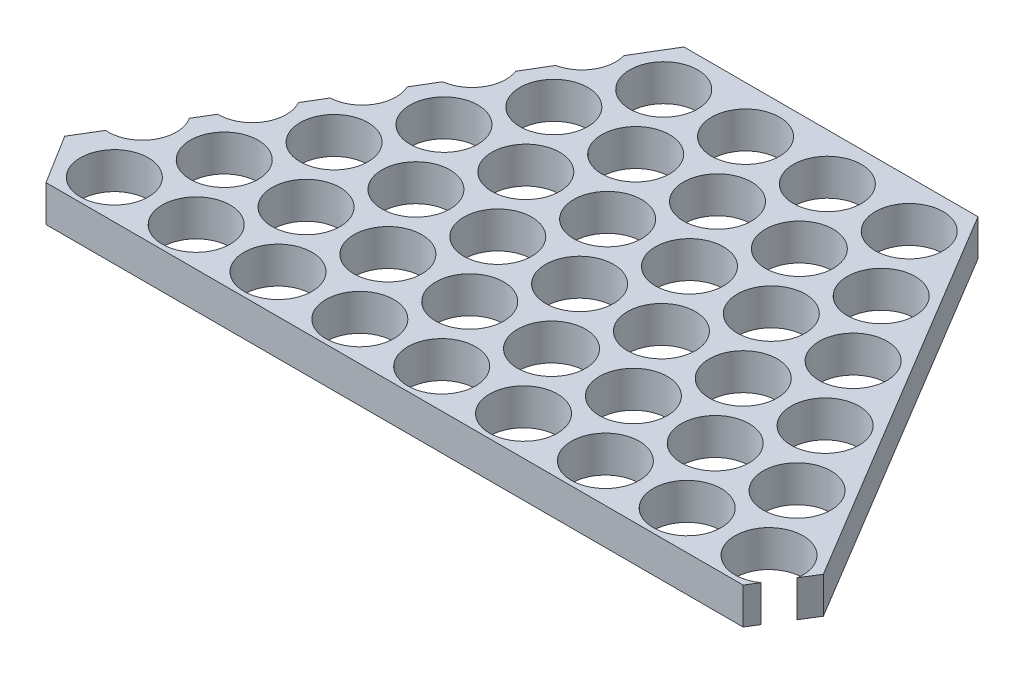
from build123d import *

# Parameters (mm, degrees)
BOSS_EXTRUDE1_DEPTH        = 2
SKETCH2_R                  = 1.868021305
CUT_EXTRUDE1_DEPTH         = 2
LPATTERN1_COUNT            = 4
LPATTERN1_PITCH            = 4.5
LPATTERN2_COUNT            = 6
LPATTERN2_PITCH            = 4.5
LPATTERN3_COUNT            = 9
LPATTERN3_PITCH            = 4.5
LPATTERN3_COPY_1_SKETCH_R  = 1.868021305
LPATTERN3_COPY_1_DEPTH     = 2
LPATTERN3_COPY_2_SKETCH_R  = 1.868021305
LPATTERN3_COPY_2_DEPTH     = 2
LPATTERN3_COPY_3_SKETCH_R  = 1.868021305
LPATTERN3_COPY_3_DEPTH     = 2
LPATTERN3_COPY_4_SKETCH_R  = 1.868021305
LPATTERN3_COPY_4_DEPTH     = 2
LPATTERN3_COPY_5_SKETCH_R  = 1.868021305
LPATTERN3_COPY_5_DEPTH     = 2
LPATTERN3_COPY_6_SKETCH_R  = 1.868021305
LPATTERN3_COPY_6_DEPTH     = 2
LPATTERN3_COPY_7_SKETCH_R  = 1.868021305
LPATTERN3_COPY_7_DEPTH     = 2
LPATTERN3_COPY_8_SKETCH_R  = 1.868021305
LPATTERN3_COPY_8_DEPTH     = 2
LPATTERN3_COPY_9_SKETCH_R  = 1.868021305
LPATTERN3_COPY_9_DEPTH     = 2
LPATTERN3_COPY_10_SKETCH_R = 1.868021305
LPATTERN3_COPY_10_DEPTH    = 2
LPATTERN3_COPY_11_SKETCH_R = 1.868021305
LPATTERN3_COPY_11_DEPTH    = 2
LPATTERN3_COPY_12_SKETCH_R = 1.868021305
LPATTERN3_COPY_12_DEPTH    = 2
LPATTERN3_COPY_13_SKETCH_R = 1.868021305
LPATTERN3_COPY_13_DEPTH    = 2
LPATTERN3_COPY_14_SKETCH_R = 1.868021305
LPATTERN3_COPY_14_DEPTH    = 2
LPATTERN3_COPY_15_SKETCH_R = 1.868021305
LPATTERN3_COPY_15_DEPTH    = 2
LPATTERN3_COPY_16_SKETCH_R = 1.868021305
LPATTERN3_COPY_16_DEPTH    = 2
LPATTERN3_COPY_17_SKETCH_R = 1.868021305
LPATTERN3_COPY_17_DEPTH    = 2
LPATTERN3_COPY_18_SKETCH_R = 1.868021305
LPATTERN3_COPY_18_DEPTH    = 2
LPATTERN3_COPY_19_SKETCH_R = 1.868021305
LPATTERN3_COPY_19_DEPTH    = 2
LPATTERN3_COPY_20_SKETCH_R = 1.868021305
LPATTERN3_COPY_20_DEPTH    = 2
LPATTERN3_COPY_21_SKETCH_R = 1.868021305
LPATTERN3_COPY_21_DEPTH    = 2
LPATTERN3_COPY_22_SKETCH_R = 1.868021305
LPATTERN3_COPY_22_DEPTH    = 2
LPATTERN3_COPY_23_SKETCH_R = 1.868021305
LPATTERN3_COPY_23_DEPTH    = 2
LPATTERN3_COPY_24_SKETCH_R = 1.868021305
LPATTERN3_COPY_24_DEPTH    = 2
LPATTERN3_COPY_25_SKETCH_R = 1.868021305
LPATTERN3_COPY_25_DEPTH    = 2
LPATTERN3_COPY_26_SKETCH_R = 1.868021305
LPATTERN3_COPY_26_DEPTH    = 2
LPATTERN3_COPY_27_SKETCH_R = 1.868021305
LPATTERN3_COPY_27_DEPTH    = 2
LPATTERN3_COPY_28_SKETCH_R = 1.868021305
LPATTERN3_COPY_28_DEPTH    = 2
LPATTERN3_COPY_29_SKETCH_R = 1.868021305
LPATTERN3_COPY_29_DEPTH    = 2
LPATTERN3_COPY_30_SKETCH_R = 1.868021305
LPATTERN3_COPY_30_DEPTH    = 2
LPATTERN3_COPY_31_SKETCH_R = 1.868021305
LPATTERN3_COPY_31_DEPTH    = 2
LPATTERN3_COPY_32_SKETCH_R = 1.868021305
LPATTERN3_COPY_32_DEPTH    = 2
LPATTERN3_COPY_33_SKETCH_R = 1.868021305
LPATTERN3_COPY_33_DEPTH    = 2
LPATTERN3_COPY_34_SKETCH_R = 1.868021305
LPATTERN3_COPY_34_DEPTH    = 2
LPATTERN3_COPY_35_SKETCH_R = 1.868021305
LPATTERN3_COPY_35_DEPTH    = 2
LPATTERN3_COPY_36_SKETCH_R = 1.868021305
LPATTERN3_COPY_36_DEPTH    = 2
LPATTERN3_COPY_37_SKETCH_R = 1.868021305
LPATTERN3_COPY_37_DEPTH    = 2
LPATTERN3_COPY_38_SKETCH_R = 1.868021305
LPATTERN3_COPY_38_DEPTH    = 2
LPATTERN3_COPY_39_SKETCH_R = 1.868021305
LPATTERN3_COPY_39_DEPTH    = 2
LPATTERN3_COPY_40_SKETCH_R = 1.868021305
LPATTERN3_COPY_40_DEPTH    = 2


with BuildPart() as part:
    # Sketch1 → Boss-Extrude1 (new body)
    with BuildSketch(Plane(origin=(0, 0, 0), x_dir=(1, 0, 0), z_dir=(0, 1, 0))):
        Polygon((8.311480428, 12), (-7.85854732, 12), (-20.632588284, -9.27790252), (-18.939417603, -12), (19.392350711, -12), (21.085521392, -9.27790252), align=None)
    extrude(amount=BOSS_EXTRUDE1_DEPTH)

    # Sketch2 → Cut-Extrude1 (cut)
    with BuildSketch(Plane(origin=(0, 2, 0), x_dir=(1, 0, 0), z_dir=(0, 1, 0))):
        with Locations((7.108541754, 9.420480397)):
            Circle(SKETCH2_R)
    cut_extrude1 = extrude(amount=-CUT_EXTRUDE1_DEPTH, mode=Mode.SUBTRACT)

    # LPattern1: Cut-Extrude1 ×4
    with Locations(*[(-i * LPATTERN1_PITCH, 0, 0) for i in range(1, LPATTERN1_COUNT)]):
        add(cut_extrude1, mode=Mode.SUBTRACT)

    # LPattern2: Cut-Extrude1 ×6
    with Locations(*[Vector(0.514712005, 0, 0.857363139) * (i * LPATTERN2_PITCH) for i in range(1, LPATTERN2_COUNT)]):
        add(cut_extrude1, mode=Mode.SUBTRACT)

    # LPattern3: Cut-Extrude1 ×9
    with Locations(*[(-i * LPATTERN3_PITCH, 0, 0) for i in range(1, LPATTERN3_COUNT)]):
        add(cut_extrude1, mode=Mode.SUBTRACT)

    # LPattern3 copy 1 sketch → LPattern3 copy 1 (cut)
    with BuildSketch(Plane(origin=(-2.183795979, 2, 3.858134126), x_dir=(1, 0, 0), z_dir=(0, 1, 0))):
        with Locations((7.108541754, 9.420480397)):
            Circle(LPATTERN3_COPY_1_SKETCH_R)
    extrude(amount=-LPATTERN3_COPY_1_DEPTH, mode=Mode.SUBTRACT)

    # LPattern3 copy 2 sketch → LPattern3 copy 2 (cut)
    with BuildSketch(Plane(origin=(-6.683795979, 2, 3.858134126), x_dir=(1, 0, 0), z_dir=(0, 1, 0))):
        with Locations((7.108541754, 9.420480397)):
            Circle(LPATTERN3_COPY_2_SKETCH_R)
    extrude(amount=-LPATTERN3_COPY_2_DEPTH, mode=Mode.SUBTRACT)

    # LPattern3 copy 3 sketch → LPattern3 copy 3 (cut)
    with BuildSketch(Plane(origin=(-11.183795979, 2, 3.858134126), x_dir=(1, 0, 0), z_dir=(0, 1, 0))):
        with Locations((7.108541754, 9.420480397)):
            Circle(LPATTERN3_COPY_3_SKETCH_R)
    extrude(amount=-LPATTERN3_COPY_3_DEPTH, mode=Mode.SUBTRACT)

    # LPattern3 copy 4 sketch → LPattern3 copy 4 (cut)
    with BuildSketch(Plane(origin=(-15.683795979, 2, 3.858134126), x_dir=(1, 0, 0), z_dir=(0, 1, 0))):
        with Locations((7.108541754, 9.420480397)):
            Circle(LPATTERN3_COPY_4_SKETCH_R)
    extrude(amount=-LPATTERN3_COPY_4_DEPTH, mode=Mode.SUBTRACT)

    # LPattern3 copy 5 sketch → LPattern3 copy 5 (cut)
    with BuildSketch(Plane(origin=(-20.183795979, 2, 3.858134126), x_dir=(1, 0, 0), z_dir=(0, 1, 0))):
        with Locations((7.108541754, 9.420480397)):
            Circle(LPATTERN3_COPY_5_SKETCH_R)
    extrude(amount=-LPATTERN3_COPY_5_DEPTH, mode=Mode.SUBTRACT)

    # LPattern3 copy 6 sketch → LPattern3 copy 6 (cut)
    with BuildSketch(Plane(origin=(-24.683795979, 2, 3.858134126), x_dir=(1, 0, 0), z_dir=(0, 1, 0))):
        with Locations((7.108541754, 9.420480397)):
            Circle(LPATTERN3_COPY_6_SKETCH_R)
    extrude(amount=-LPATTERN3_COPY_6_DEPTH, mode=Mode.SUBTRACT)

    # LPattern3 copy 7 sketch → LPattern3 copy 7 (cut)
    with BuildSketch(Plane(origin=(-29.183795979, 2, 3.858134126), x_dir=(1, 0, 0), z_dir=(0, 1, 0))):
        with Locations((7.108541754, 9.420480397)):
            Circle(LPATTERN3_COPY_7_SKETCH_R)
    extrude(amount=-LPATTERN3_COPY_7_DEPTH, mode=Mode.SUBTRACT)

    # LPattern3 copy 8 sketch → LPattern3 copy 8 (cut)
    with BuildSketch(Plane(origin=(-33.683795979, 2, 3.858134126), x_dir=(1, 0, 0), z_dir=(0, 1, 0))):
        with Locations((7.108541754, 9.420480397)):
            Circle(LPATTERN3_COPY_8_SKETCH_R)
    extrude(amount=-LPATTERN3_COPY_8_DEPTH, mode=Mode.SUBTRACT)

    # LPattern3 copy 9 sketch → LPattern3 copy 9 (cut)
    with BuildSketch(Plane(origin=(0.132408042, 2, 7.716268252), x_dir=(1, 0, 0), z_dir=(0, 1, 0))):
        with Locations((7.108541754, 9.420480397)):
            Circle(LPATTERN3_COPY_9_SKETCH_R)
    extrude(amount=-LPATTERN3_COPY_9_DEPTH, mode=Mode.SUBTRACT)

    # LPattern3 copy 10 sketch → LPattern3 copy 10 (cut)
    with BuildSketch(Plane(origin=(-4.367591958, 2, 7.716268252), x_dir=(1, 0, 0), z_dir=(0, 1, 0))):
        with Locations((7.108541754, 9.420480397)):
            Circle(LPATTERN3_COPY_10_SKETCH_R)
    extrude(amount=-LPATTERN3_COPY_10_DEPTH, mode=Mode.SUBTRACT)

    # LPattern3 copy 11 sketch → LPattern3 copy 11 (cut)
    with BuildSketch(Plane(origin=(-8.867591958, 2, 7.716268252), x_dir=(1, 0, 0), z_dir=(0, 1, 0))):
        with Locations((7.108541754, 9.420480397)):
            Circle(LPATTERN3_COPY_11_SKETCH_R)
    extrude(amount=-LPATTERN3_COPY_11_DEPTH, mode=Mode.SUBTRACT)

    # LPattern3 copy 12 sketch → LPattern3 copy 12 (cut)
    with BuildSketch(Plane(origin=(-13.367591958, 2, 7.716268252), x_dir=(1, 0, 0), z_dir=(0, 1, 0))):
        with Locations((7.108541754, 9.420480397)):
            Circle(LPATTERN3_COPY_12_SKETCH_R)
    extrude(amount=-LPATTERN3_COPY_12_DEPTH, mode=Mode.SUBTRACT)

    # LPattern3 copy 13 sketch → LPattern3 copy 13 (cut)
    with BuildSketch(Plane(origin=(-17.867591958, 2, 7.716268252), x_dir=(1, 0, 0), z_dir=(0, 1, 0))):
        with Locations((7.108541754, 9.420480397)):
            Circle(LPATTERN3_COPY_13_SKETCH_R)
    extrude(amount=-LPATTERN3_COPY_13_DEPTH, mode=Mode.SUBTRACT)

    # LPattern3 copy 14 sketch → LPattern3 copy 14 (cut)
    with BuildSketch(Plane(origin=(-22.367591958, 2, 7.716268252), x_dir=(1, 0, 0), z_dir=(0, 1, 0))):
        with Locations((7.108541754, 9.420480397)):
            Circle(LPATTERN3_COPY_14_SKETCH_R)
    extrude(amount=-LPATTERN3_COPY_14_DEPTH, mode=Mode.SUBTRACT)

    # LPattern3 copy 15 sketch → LPattern3 copy 15 (cut)
    with BuildSketch(Plane(origin=(-26.867591958, 2, 7.716268252), x_dir=(1, 0, 0), z_dir=(0, 1, 0))):
        with Locations((7.108541754, 9.420480397)):
            Circle(LPATTERN3_COPY_15_SKETCH_R)
    extrude(amount=-LPATTERN3_COPY_15_DEPTH, mode=Mode.SUBTRACT)

    # LPattern3 copy 16 sketch → LPattern3 copy 16 (cut)
    with BuildSketch(Plane(origin=(-31.367591958, 2, 7.716268252), x_dir=(1, 0, 0), z_dir=(0, 1, 0))):
        with Locations((7.108541754, 9.420480397)):
            Circle(LPATTERN3_COPY_16_SKETCH_R)
    extrude(amount=-LPATTERN3_COPY_16_DEPTH, mode=Mode.SUBTRACT)

    # LPattern3 copy 17 sketch → LPattern3 copy 17 (cut)
    with BuildSketch(Plane(origin=(2.448612062, 2, 11.574402378), x_dir=(1, 0, 0), z_dir=(0, 1, 0))):
        with Locations((7.108541754, 9.420480397)):
            Circle(LPATTERN3_COPY_17_SKETCH_R)
    extrude(amount=-LPATTERN3_COPY_17_DEPTH, mode=Mode.SUBTRACT)

    # LPattern3 copy 18 sketch → LPattern3 copy 18 (cut)
    with BuildSketch(Plane(origin=(-2.051387938, 2, 11.574402378), x_dir=(1, 0, 0), z_dir=(0, 1, 0))):
        with Locations((7.108541754, 9.420480397)):
            Circle(LPATTERN3_COPY_18_SKETCH_R)
    extrude(amount=-LPATTERN3_COPY_18_DEPTH, mode=Mode.SUBTRACT)

    # LPattern3 copy 19 sketch → LPattern3 copy 19 (cut)
    with BuildSketch(Plane(origin=(-6.551387938, 2, 11.574402378), x_dir=(1, 0, 0), z_dir=(0, 1, 0))):
        with Locations((7.108541754, 9.420480397)):
            Circle(LPATTERN3_COPY_19_SKETCH_R)
    extrude(amount=-LPATTERN3_COPY_19_DEPTH, mode=Mode.SUBTRACT)

    # LPattern3 copy 20 sketch → LPattern3 copy 20 (cut)
    with BuildSketch(Plane(origin=(-11.051387938, 2, 11.574402378), x_dir=(1, 0, 0), z_dir=(0, 1, 0))):
        with Locations((7.108541754, 9.420480397)):
            Circle(LPATTERN3_COPY_20_SKETCH_R)
    extrude(amount=-LPATTERN3_COPY_20_DEPTH, mode=Mode.SUBTRACT)

    # LPattern3 copy 21 sketch → LPattern3 copy 21 (cut)
    with BuildSketch(Plane(origin=(-15.551387938, 2, 11.574402378), x_dir=(1, 0, 0), z_dir=(0, 1, 0))):
        with Locations((7.108541754, 9.420480397)):
            Circle(LPATTERN3_COPY_21_SKETCH_R)
    extrude(amount=-LPATTERN3_COPY_21_DEPTH, mode=Mode.SUBTRACT)

    # LPattern3 copy 22 sketch → LPattern3 copy 22 (cut)
    with BuildSketch(Plane(origin=(-20.051387938, 2, 11.574402378), x_dir=(1, 0, 0), z_dir=(0, 1, 0))):
        with Locations((7.108541754, 9.420480397)):
            Circle(LPATTERN3_COPY_22_SKETCH_R)
    extrude(amount=-LPATTERN3_COPY_22_DEPTH, mode=Mode.SUBTRACT)

    # LPattern3 copy 23 sketch → LPattern3 copy 23 (cut)
    with BuildSketch(Plane(origin=(-24.551387938, 2, 11.574402378), x_dir=(1, 0, 0), z_dir=(0, 1, 0))):
        with Locations((7.108541754, 9.420480397)):
            Circle(LPATTERN3_COPY_23_SKETCH_R)
    extrude(amount=-LPATTERN3_COPY_23_DEPTH, mode=Mode.SUBTRACT)

    # LPattern3 copy 24 sketch → LPattern3 copy 24 (cut)
    with BuildSketch(Plane(origin=(-29.051387938, 2, 11.574402378), x_dir=(1, 0, 0), z_dir=(0, 1, 0))):
        with Locations((7.108541754, 9.420480397)):
            Circle(LPATTERN3_COPY_24_SKETCH_R)
    extrude(amount=-LPATTERN3_COPY_24_DEPTH, mode=Mode.SUBTRACT)

    # LPattern3 copy 25 sketch → LPattern3 copy 25 (cut)
    with BuildSketch(Plane(origin=(4.764816083, 2, 15.432536504), x_dir=(1, 0, 0), z_dir=(0, 1, 0))):
        with Locations((7.108541754, 9.420480397)):
            Circle(LPATTERN3_COPY_25_SKETCH_R)
    extrude(amount=-LPATTERN3_COPY_25_DEPTH, mode=Mode.SUBTRACT)

    # LPattern3 copy 26 sketch → LPattern3 copy 26 (cut)
    with BuildSketch(Plane(origin=(0.264816083, 2, 15.432536504), x_dir=(1, 0, 0), z_dir=(0, 1, 0))):
        with Locations((7.108541754, 9.420480397)):
            Circle(LPATTERN3_COPY_26_SKETCH_R)
    extrude(amount=-LPATTERN3_COPY_26_DEPTH, mode=Mode.SUBTRACT)

    # LPattern3 copy 27 sketch → LPattern3 copy 27 (cut)
    with BuildSketch(Plane(origin=(-4.235183917, 2, 15.432536504), x_dir=(1, 0, 0), z_dir=(0, 1, 0))):
        with Locations((7.108541754, 9.420480397)):
            Circle(LPATTERN3_COPY_27_SKETCH_R)
    extrude(amount=-LPATTERN3_COPY_27_DEPTH, mode=Mode.SUBTRACT)

    # LPattern3 copy 28 sketch → LPattern3 copy 28 (cut)
    with BuildSketch(Plane(origin=(-8.735183917, 2, 15.432536504), x_dir=(1, 0, 0), z_dir=(0, 1, 0))):
        with Locations((7.108541754, 9.420480397)):
            Circle(LPATTERN3_COPY_28_SKETCH_R)
    extrude(amount=-LPATTERN3_COPY_28_DEPTH, mode=Mode.SUBTRACT)

    # LPattern3 copy 29 sketch → LPattern3 copy 29 (cut)
    with BuildSketch(Plane(origin=(-13.235183917, 2, 15.432536504), x_dir=(1, 0, 0), z_dir=(0, 1, 0))):
        with Locations((7.108541754, 9.420480397)):
            Circle(LPATTERN3_COPY_29_SKETCH_R)
    extrude(amount=-LPATTERN3_COPY_29_DEPTH, mode=Mode.SUBTRACT)

    # LPattern3 copy 30 sketch → LPattern3 copy 30 (cut)
    with BuildSketch(Plane(origin=(-17.735183917, 2, 15.432536504), x_dir=(1, 0, 0), z_dir=(0, 1, 0))):
        with Locations((7.108541754, 9.420480397)):
            Circle(LPATTERN3_COPY_30_SKETCH_R)
    extrude(amount=-LPATTERN3_COPY_30_DEPTH, mode=Mode.SUBTRACT)

    # LPattern3 copy 31 sketch → LPattern3 copy 31 (cut)
    with BuildSketch(Plane(origin=(-22.235183917, 2, 15.432536504), x_dir=(1, 0, 0), z_dir=(0, 1, 0))):
        with Locations((7.108541754, 9.420480397)):
            Circle(LPATTERN3_COPY_31_SKETCH_R)
    extrude(amount=-LPATTERN3_COPY_31_DEPTH, mode=Mode.SUBTRACT)

    # LPattern3 copy 32 sketch → LPattern3 copy 32 (cut)
    with BuildSketch(Plane(origin=(-26.735183917, 2, 15.432536504), x_dir=(1, 0, 0), z_dir=(0, 1, 0))):
        with Locations((7.108541754, 9.420480397)):
            Circle(LPATTERN3_COPY_32_SKETCH_R)
    extrude(amount=-LPATTERN3_COPY_32_DEPTH, mode=Mode.SUBTRACT)

    # LPattern3 copy 33 sketch → LPattern3 copy 33 (cut)
    with BuildSketch(Plane(origin=(7.081020104, 2, 19.29067063), x_dir=(1, 0, 0), z_dir=(0, 1, 0))):
        with Locations((7.108541754, 9.420480397)):
            Circle(LPATTERN3_COPY_33_SKETCH_R)
    extrude(amount=-LPATTERN3_COPY_33_DEPTH, mode=Mode.SUBTRACT)

    # LPattern3 copy 34 sketch → LPattern3 copy 34 (cut)
    with BuildSketch(Plane(origin=(2.581020104, 2, 19.29067063), x_dir=(1, 0, 0), z_dir=(0, 1, 0))):
        with Locations((7.108541754, 9.420480397)):
            Circle(LPATTERN3_COPY_34_SKETCH_R)
    extrude(amount=-LPATTERN3_COPY_34_DEPTH, mode=Mode.SUBTRACT)

    # LPattern3 copy 35 sketch → LPattern3 copy 35 (cut)
    with BuildSketch(Plane(origin=(-1.918979896, 2, 19.29067063), x_dir=(1, 0, 0), z_dir=(0, 1, 0))):
        with Locations((7.108541754, 9.420480397)):
            Circle(LPATTERN3_COPY_35_SKETCH_R)
    extrude(amount=-LPATTERN3_COPY_35_DEPTH, mode=Mode.SUBTRACT)

    # LPattern3 copy 36 sketch → LPattern3 copy 36 (cut)
    with BuildSketch(Plane(origin=(-6.418979896, 2, 19.29067063), x_dir=(1, 0, 0), z_dir=(0, 1, 0))):
        with Locations((7.108541754, 9.420480397)):
            Circle(LPATTERN3_COPY_36_SKETCH_R)
    extrude(amount=-LPATTERN3_COPY_36_DEPTH, mode=Mode.SUBTRACT)

    # LPattern3 copy 37 sketch → LPattern3 copy 37 (cut)
    with BuildSketch(Plane(origin=(-10.918979896, 2, 19.29067063), x_dir=(1, 0, 0), z_dir=(0, 1, 0))):
        with Locations((7.108541754, 9.420480397)):
            Circle(LPATTERN3_COPY_37_SKETCH_R)
    extrude(amount=-LPATTERN3_COPY_37_DEPTH, mode=Mode.SUBTRACT)

    # LPattern3 copy 38 sketch → LPattern3 copy 38 (cut)
    with BuildSketch(Plane(origin=(-15.418979896, 2, 19.29067063), x_dir=(1, 0, 0), z_dir=(0, 1, 0))):
        with Locations((7.108541754, 9.420480397)):
            Circle(LPATTERN3_COPY_38_SKETCH_R)
    extrude(amount=-LPATTERN3_COPY_38_DEPTH, mode=Mode.SUBTRACT)

    # LPattern3 copy 39 sketch → LPattern3 copy 39 (cut)
    with BuildSketch(Plane(origin=(-19.918979896, 2, 19.29067063), x_dir=(1, 0, 0), z_dir=(0, 1, 0))):
        with Locations((7.108541754, 9.420480397)):
            Circle(LPATTERN3_COPY_39_SKETCH_R)
    extrude(amount=-LPATTERN3_COPY_39_DEPTH, mode=Mode.SUBTRACT)

    # LPattern3 copy 40 sketch → LPattern3 copy 40 (cut)
    with BuildSketch(Plane(origin=(-24.418979896, 2, 19.29067063), x_dir=(1, 0, 0), z_dir=(0, 1, 0))):
        with Locations((7.108541754, 9.420480397)):
            Circle(LPATTERN3_COPY_40_SKETCH_R)
    extrude(amount=-LPATTERN3_COPY_40_DEPTH, mode=Mode.SUBTRACT)


solid = part.part
